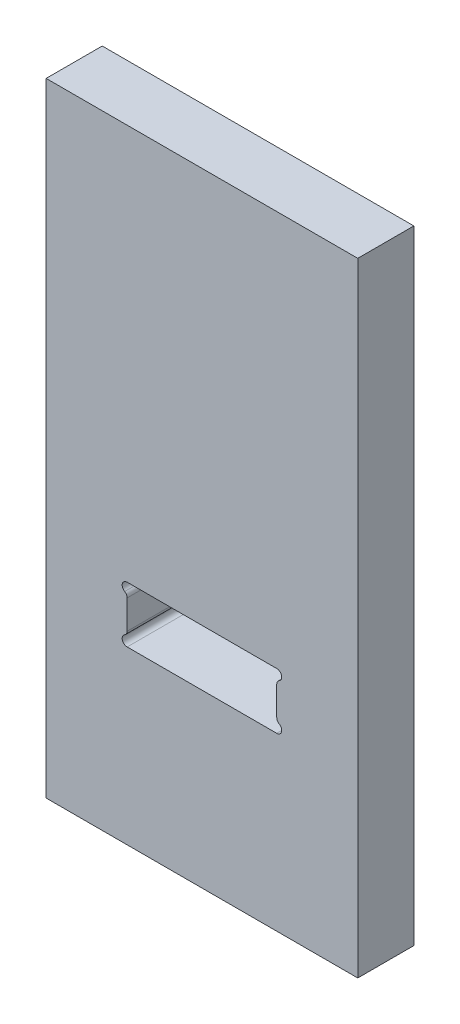
from build123d import *

# Parameters (mm, degrees)
SKETCH1_W           = 25
SKETCH1_H           = 50
BOSS_EXTRUDE1_DEPTH = 4.5
CUT_EXTRUDE2_REACH  = 6.5


with BuildPart() as part:
    # Sketch1 → Boss-Extrude1 (new body)
    with BuildSketch(Plane.XY):
        with Locations((12.5, 25)):
            Rectangle(SKETCH1_W, SKETCH1_H)
    extrude(amount=BOSS_EXTRUDE1_DEPTH)

    # Sketch3 → Cut-Extrude2 (cut, up to next)
    with BuildSketch(Plane.XY.offset(4.5), mode=Mode.PRIVATE) as cut_extrude2_sk1:
        with BuildLine():
            Line((6.5, 18.25), (18.5, 18.25))
            ThreePointArc((18.5, 18.25), (18.886370331, 17.953527618), (18.7, 17.503589838))
            ThreePointArc((18.7, 17.503589838), (18.553589838, 17.357179677), (18.5, 17.157179677))
            Line((18.5, 17.157179677), (18.5, 14.842820323))
            ThreePointArc((18.5, 14.842820323), (18.553589838, 14.642820323), (18.7, 14.496410162))
            ThreePointArc((18.7, 14.496410162), (18.886370331, 14.046472382), (18.5, 13.75))
            Line((18.5, 13.75), (6.5, 13.75))
            ThreePointArc((6.5, 13.75), (6.113629669, 14.046472382), (6.3, 14.496410162))
            ThreePointArc((6.3, 14.496410162), (6.446410162, 14.642820323), (6.5, 14.842820323))
            Line((6.5, 14.842820323), (6.5, 17.157179677))
            ThreePointArc((6.5, 17.157179677), (6.446410162, 17.357179677), (6.3, 17.503589838))
            ThreePointArc((6.3, 17.503589838), (6.113629669, 17.953527618), (6.5, 18.25))
        make_face()
    cut_extrude2_tool1 = extrude(cut_extrude2_sk1.sketch, amount=-CUT_EXTRUDE2_REACH, mode=Mode.PRIVATE) & part.part
    add(cut_extrude2_tool1.solids().sort_by_distance((12.5, 16, 4.5))[0], mode=Mode.SUBTRACT)


solid = part.part
